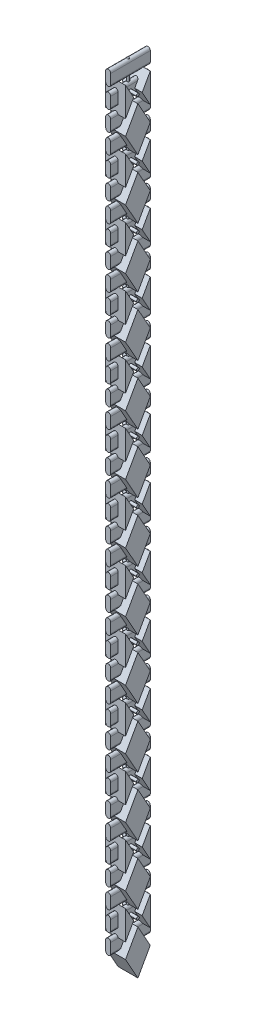
from build123d import *

# Parameters (mm, degrees)
BOSS_EXTRUDE1_DEPTH   = 25.4
BOSS_EXTRUDE1_2_DEPTH = 25.4
BOSS_EXTRUDE1_3_DEPTH = 25.4
BOSS_EXTRUDE2_DEPTH   = 50.8
SKETCH4_R             = 1.778
BOSS_EXTRUDE4_DEPTH   = 25.4
LPATTERN1_COUNT       = 13
LPATTERN1_PITCH       = 76.2
SKETCH3_R             = 1.5875
BOSS_EXTRUDE3_DEPTH   = 987.425


with BuildPart() as part:
    # Sketch1 → Boss-Extrude1 (new body)
    with BuildSketch(Plane(origin=(0, 0, 0), x_dir=(0, 0, -1), z_dir=(1, 0, 0))):
        Polygon((9.525, 0), (25.4, 28.351872615), (41.275, 0), (25.4, -28.351872615), align=None)
    extrude(amount=BOSS_EXTRUDE1_DEPTH)



with BuildPart() as body_2:
    # Sketch1 → Boss-Extrude1 2 (new body)
    with BuildSketch(Plane(origin=(0, 0, 0), x_dir=(0, 0, -1), z_dir=(1, 0, 0))):
        Polygon((9.525, 19.49625477), (9.525, 56.70374523), (19.941753049, 38.1), align=None)
    extrude(amount=BOSS_EXTRUDE1_2_DEPTH)


with BuildPart() as body_3:
    # Sketch1 → Boss-Extrude1 3 (new body)
    with BuildSketch(Plane(origin=(0, 0, 0), x_dir=(0, 0, -1), z_dir=(1, 0, 0))):
        Polygon((41.275, 56.70374523), (41.275, 19.49625477), (30.858246951, 38.1), align=None)
    extrude(amount=BOSS_EXTRUDE1_3_DEPTH)


with BuildPart() as part_1:
    add(part.part)

    add(body_2.part)  # Boss-Extrude2 merges body 2

    add(body_3.part)  # Boss-Extrude2 merges body 3
    # Sketch2 → Boss-Extrude2 (add)
    with BuildSketch(Plane.XY):
        with BuildLine():
            Line((9.525, 6.35), (9.525, 19.05))
            ThreePointArc((9.525, 19.05), (12.7, 22.225), (15.875, 19.05))
            Line((15.875, 19.05), (15.875, 6.35))
            ThreePointArc((15.875, 6.35), (12.7, 3.175), (9.525, 6.35))
        make_face()
        with BuildLine():
            Line((9.525, 31.75), (9.525, 44.45))
            ThreePointArc((9.525, 44.45), (12.7, 47.625), (15.875, 44.45))
            Line((15.875, 44.45), (15.875, 31.75))
            ThreePointArc((15.875, 31.75), (12.7, 28.575), (9.525, 31.75))
        make_face()
        with BuildLine():
            Line((9.525, 57.15), (9.525, 69.85))
            ThreePointArc((9.525, 69.85), (12.7, 73.025), (15.875, 69.85))
            Line((15.875, 69.85), (15.875, 57.15))
            ThreePointArc((15.875, 57.15), (12.7, 53.975), (9.525, 57.15))
        make_face()
    extrude(amount=-BOSS_EXTRUDE2_DEPTH)

    # Sketch4 → Boss-Extrude4 (add)
    with BuildSketch(Plane(origin=(0, 0, 0), x_dir=(0, 0, -1), z_dir=(1, 0, 0))):
        with Locations((25.4, 38.1)):
            Circle(SKETCH4_R)
    extrude(amount=BOSS_EXTRUDE4_DEPTH)


with BuildPart() as lpattern1_1:
    # LPattern1: pattern copy
    add(part_1.part.moved(Location(Vector(0, 1, 0) * (1 * LPATTERN1_PITCH))))


with BuildPart() as lpattern1_2:
    # LPattern1: pattern copy
    add(part_1.part.moved(Location(Vector(0, 1, 0) * (2 * LPATTERN1_PITCH))))


with BuildPart() as lpattern1_3:
    # LPattern1: pattern copy
    add(part_1.part.moved(Location(Vector(0, 1, 0) * (3 * LPATTERN1_PITCH))))


with BuildPart() as lpattern1_4:
    # LPattern1: pattern copy
    add(part_1.part.moved(Location(Vector(0, 1, 0) * (4 * LPATTERN1_PITCH))))


with BuildPart() as lpattern1_5:
    # LPattern1: pattern copy
    add(part_1.part.moved(Location(Vector(0, 1, 0) * (5 * LPATTERN1_PITCH))))


with BuildPart() as lpattern1_6:
    # LPattern1: pattern copy
    add(part_1.part.moved(Location(Vector(0, 1, 0) * (6 * LPATTERN1_PITCH))))


with BuildPart() as lpattern1_7:
    # LPattern1: pattern copy
    add(part_1.part.moved(Location(Vector(0, 1, 0) * (7 * LPATTERN1_PITCH))))


with BuildPart() as lpattern1_8:
    # LPattern1: pattern copy
    add(part_1.part.moved(Location(Vector(0, 1, 0) * (8 * LPATTERN1_PITCH))))


with BuildPart() as lpattern1_9:
    # LPattern1: pattern copy
    add(part_1.part.moved(Location(Vector(0, 1, 0) * (9 * LPATTERN1_PITCH))))


with BuildPart() as lpattern1_10:
    # LPattern1: pattern copy
    add(part_1.part.moved(Location(Vector(0, 1, 0) * (10 * LPATTERN1_PITCH))))


with BuildPart() as lpattern1_11:
    # LPattern1: pattern copy
    add(part_1.part.moved(Location(Vector(0, 1, 0) * (11 * LPATTERN1_PITCH))))


with BuildPart() as lpattern1_12:
    # LPattern1: pattern copy
    add(part_1.part.moved(Location(Vector(0, 1, 0) * (12 * LPATTERN1_PITCH))))


with BuildPart() as part_2:
    add(part_1.part)

    add(lpattern1_1.part)  # Boss-Extrude3 merges LPattern1_1

    add(lpattern1_2.part)  # Boss-Extrude3 merges LPattern1_2

    add(lpattern1_3.part)  # Boss-Extrude3 merges LPattern1_3

    add(lpattern1_4.part)  # Boss-Extrude3 merges LPattern1_4

    add(lpattern1_5.part)  # Boss-Extrude3 merges LPattern1_5

    add(lpattern1_6.part)  # Boss-Extrude3 merges LPattern1_6

    add(lpattern1_7.part)  # Boss-Extrude3 merges LPattern1_7

    add(lpattern1_8.part)  # Boss-Extrude3 merges LPattern1_8

    add(lpattern1_9.part)  # Boss-Extrude3 merges LPattern1_9

    add(lpattern1_10.part)  # Boss-Extrude3 merges LPattern1_10

    add(lpattern1_11.part)  # Boss-Extrude3 merges LPattern1_11

    add(lpattern1_12.part)  # Boss-Extrude3 merges LPattern1_12
    # Sketch3 → Boss-Extrude3 (add, through all)
    with BuildSketch(Plane(origin=(0, 0, 0), x_dir=(1, 0, 0), z_dir=(0, 1, 0))):
        with Locations((12.7, 25.4)):
            Circle(SKETCH3_R)
    extrude(amount=BOSS_EXTRUDE3_DEPTH)


solid = part_2.part
